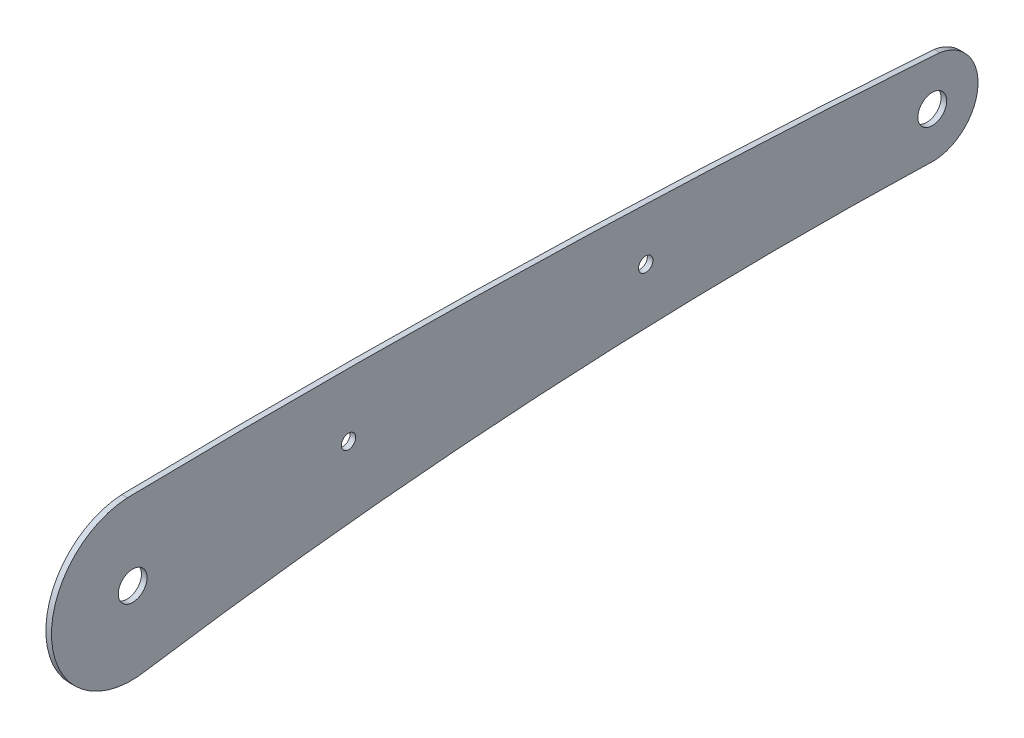
from build123d import *

# Parameters (mm, degrees)
SKETCH_1_R      = 3.85
SKETCH_1_R_2    = 1.925
EXTRUDE_1_DEPTH = 1.5


with BuildPart() as part:
    # 草圖1 → 填料-伸長1 (new body)
    with BuildSketch(Plane(origin=(0, 0, 0), x_dir=(0, 0, -1), z_dir=(1, 0, 0))):
        with BuildLine():
            ThreePointArc((111.555989952, -8.572011863), (6.374730125, -10.137132711), (-98.230068302, -21.244930328))
            ThreePointArc((-98.230068302, -21.244930328), (-123.67575498, -2.873316644), (-103.541794939, 21.20204032))
            ThreePointArc((-103.541794939, 21.20204032), (5.082777822, 20.871677912), (113.584507189, 15.696576829))
            ThreePointArc((113.584507189, 15.696576829), (123.827345593, 3.028727453), (112.406990492, -8.588743688))
            ThreePointArc((112.406990492, -8.588743688), (111.981133536, -8.59851924), (111.555989952, -8.572011863))
        make_face()
        with Locations((-102.143981395, 0.133331517)):
            Circle(SKETCH_1_R, mode=Mode.SUBTRACT)
        with Locations((35.001055541, 5.982881827)):
            Circle(SKETCH_1_R_2, mode=Mode.SUBTRACT)
        with Locations((-44.432813653, 4.686665047)):
            Circle(SKETCH_1_R_2, mode=Mode.SUBTRACT)
        with Locations((111.605339346, 3.621333032)):
            Circle(SKETCH_1_R, mode=Mode.SUBTRACT)
    extrude(amount=EXTRUDE_1_DEPTH)


solid = part.part
